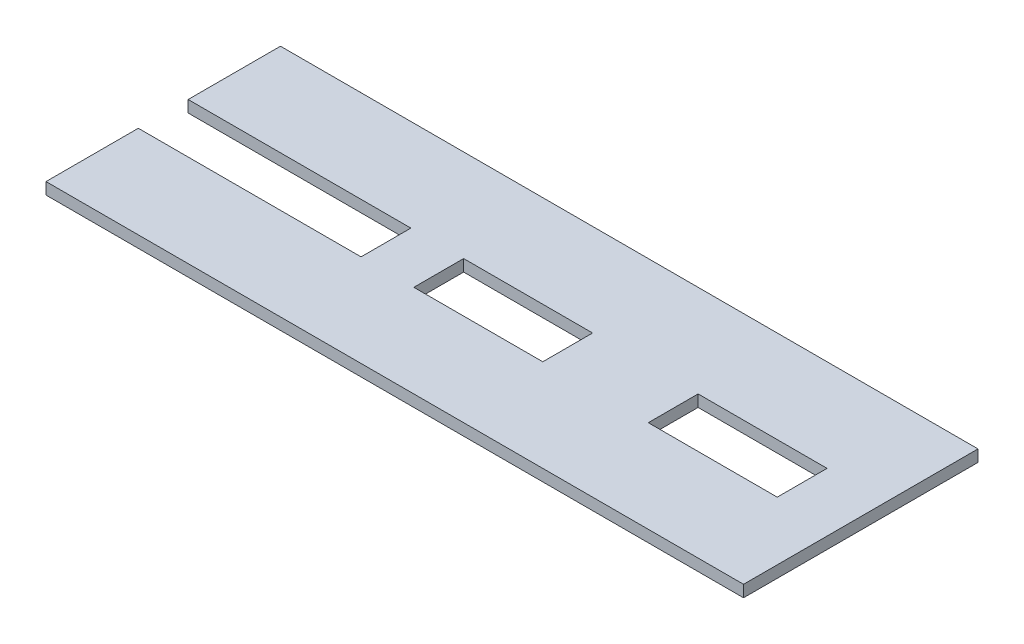
from build123d import *

# Parameters (mm, degrees)
SKETCH1_W           = 119
SKETCH1_H           = 40
BOSS_EXTRUDE1_DEPTH = 2
SKETCH2_W           = 38
SKETCH2_H           = 8.5
CUT_EXTRUDE1_DEPTH  = 3
SKETCH3_W           = 22
SKETCH3_H           = 8.5
CUT_EXTRUDE2_DEPTH  = 3


with BuildPart() as part:
    # Sketch1 → Boss-Extrude1 (new body)
    with BuildSketch(Plane(origin=(0, 0, 0), x_dir=(1, 0, 0), z_dir=(0, 1, 0))):
        with Locations((59.5, -20)):
            Rectangle(SKETCH1_W, SKETCH1_H)
    extrude(amount=BOSS_EXTRUDE1_DEPTH)

    # Sketch2 → Cut-Extrude1 (cut, through all)
    with BuildSketch(Plane(origin=(0, 2, 0), x_dir=(1, 0, 0), z_dir=(0, 1, 0))):
        with Locations((19, -20)):
            Rectangle(SKETCH2_W, SKETCH2_H)
    extrude(amount=-CUT_EXTRUDE1_DEPTH, mode=Mode.SUBTRACT)

    # Sketch3 → Cut-Extrude2 (cut, through all)
    with BuildSketch(Plane(origin=(0, 2, 0), x_dir=(1, 0, 0), z_dir=(0, 1, 0))):
        with Locations((58, -20)):
            Rectangle(SKETCH3_W, SKETCH3_H)
        with Locations((98, -20)):
            Rectangle(SKETCH3_W, SKETCH3_H)
    extrude(amount=-CUT_EXTRUDE2_DEPTH, mode=Mode.SUBTRACT)


solid = part.part
